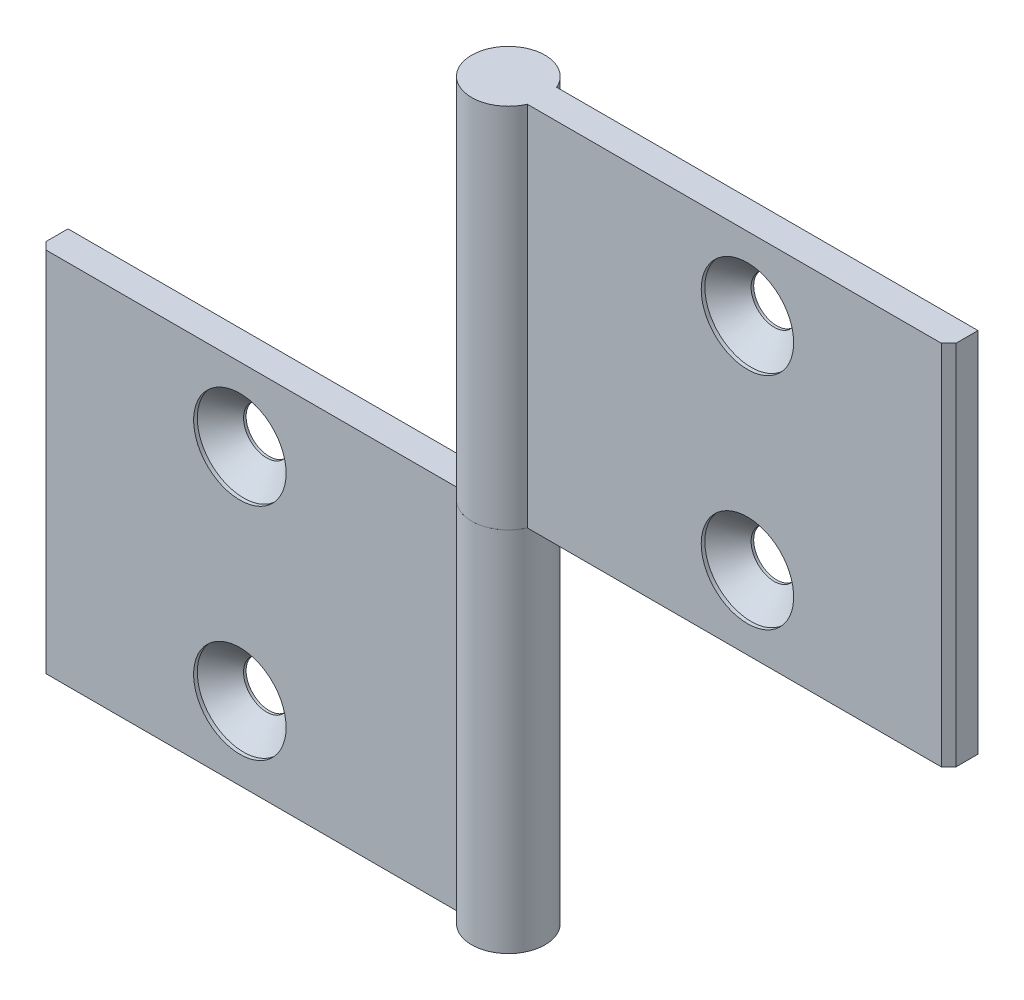
from build123d import *

# Parameters (mm, degrees)
EXTRUDE_1_DEPTH            = 25
HOLE_WIZARD_M61_AT_2_COUNT = 2
HOLE_WIZARD_M61_AT_2_PITCH = 30
PATTERN_CIRCULAR_1_COUNT   = 2


with BuildPart() as part:
    # Эскиз1 → Бобышка-Вытянуть1 (new body, symmetric)
    with BuildSketch(Plane(origin=(0, 0, 0), x_dir=(1, 0, 0), z_dir=(0, 1, 0))):
        with BuildLine():
            Line((-4.582575695, 2), (-62, 2))
            Line((-62, 2), (-62, -1))
            Line((-62, -1), (-61, -2))
            Line((-61, -2), (-4.582575695, -2))
            ThreePointArc((-4.582575695, -2), (5, 0), (-4.582575695, 2))
        make_face()
    extrude(amount=EXTRUDE_1_DEPTH, both=True)

    # Эскиз6 → Зенковка для винта с полупотайной головкой M61 (revolve, cut)
    with BuildSketch(Plane(origin=(-34.582575695, 15, 2), x_dir=(0, -1, 0), z_dir=(1, 0, 0))):
        Polygon((0, 0), (0, 7), (3.15, 7), (3.15, 3.65), (6.3, 0.5), (6.3, 0), align=None)
    hole_wizard_m61 = revolve(axis=Axis((-34.582575695, 15, 8.35), (0, 0, -1)), mode=Mode.SUBTRACT)

    # Зенковка для винта с полупотайной головкой M61 at 2: Зенковка для винта с полупотайной головкой M61 ×2
    with Locations(*[(0, -i * HOLE_WIZARD_M61_AT_2_PITCH, 0) for i in range(1, HOLE_WIZARD_M61_AT_2_COUNT)]):
        add(hole_wizard_m61, mode=Mode.SUBTRACT)


with BuildPart() as pattern_circular_1_1:
    # Круговой массив1: pattern copy
    add(part.part.rotate(Axis((0, 25, 0), (0, 0, 1)), 1 * 360 / PATTERN_CIRCULAR_1_COUNT))


solid = Compound([part.part, pattern_circular_1_1.part])
